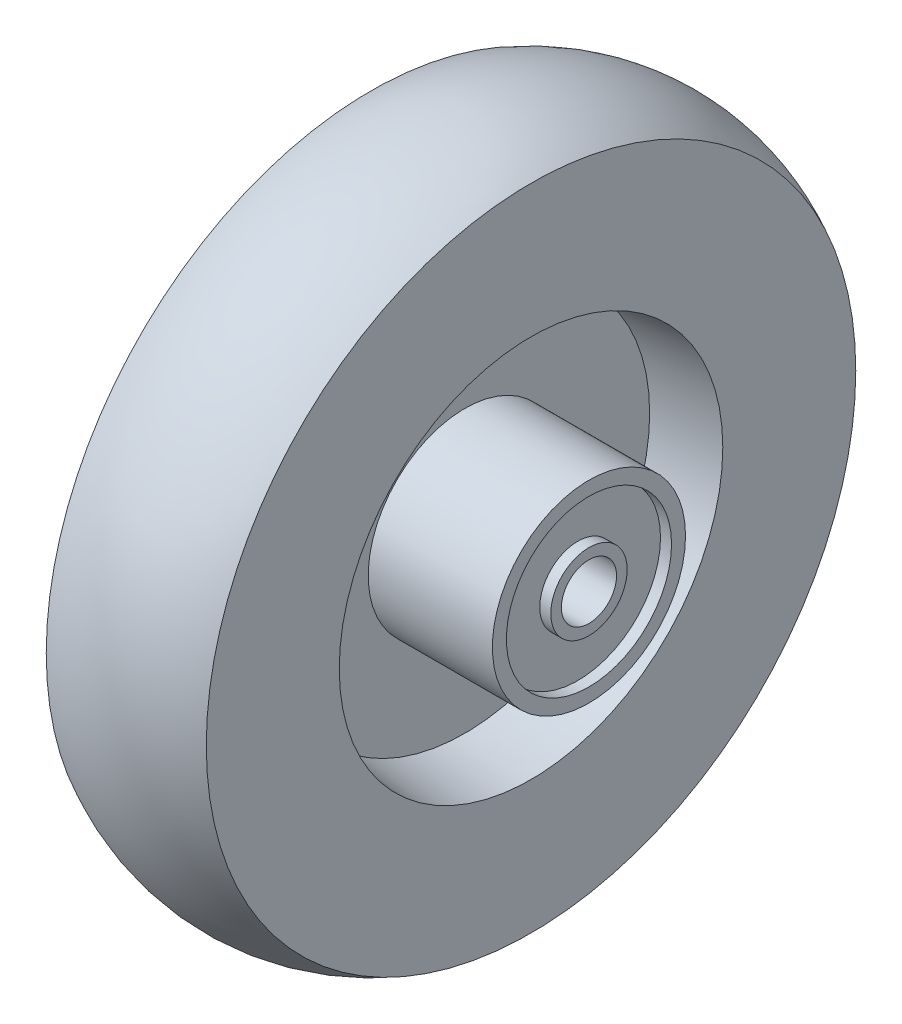
from build123d import *

# Parameters (mm, degrees)
SKETCH2_R          = 19.001809039
SKETCH2_R_2        = 8.788318948
CUT_EXTRUDE1_DEPTH = 2.54
SKETCH3_R          = 6.35
CUT_EXTRUDE2_DEPTH = 64.5


with BuildPart() as part:
    # Sketch1 → Revolve1 (revolve)
    with BuildSketch(Plane(origin=(0, 0, 0), x_dir=(1, 0, 0), z_dir=(0, 1, 0))):
        with BuildLine():
            Line((-31.75, 22.225), (-31.75, 0))
            Line((-31.75, 0), (31.75, 0))
            Line((31.75, 0), (31.75, 22.225))
            Line((31.75, 22.225), (3.175, 22.225))
            Line((3.175, 22.225), (3.175, 42.545))
            Line((3.175, 42.545), (18.415, 44.136059808))
            Line((18.415, 44.136059808), (18.415, 74.737433252))
            ThreePointArc((18.415, 74.737433252), (0, 79.375), (-18.415, 74.737433252))
            Line((-18.415, 74.737433252), (-18.415, 44.136059808))
            Line((-18.415, 44.136059808), (-3.175, 42.545))
            Line((-3.175, 42.545), (-3.175, 22.225))
            Line((-3.175, 22.225), (-31.75, 22.225))
        make_face()
    revolve(axis=Axis((-31.75, 0, 0), (-1, 0, 0)))

    # Sketch2 → Cut-Extrude1 (cut)
    with BuildSketch(Plane(origin=(31.75, 0, 0), x_dir=(0, 0, -1), z_dir=(1, 0, 0))):
        Circle(SKETCH2_R)
        Circle(SKETCH2_R_2, mode=Mode.SUBTRACT)
    cut_extrude1 = extrude(amount=-CUT_EXTRUDE1_DEPTH, mode=Mode.SUBTRACT)

    # Sketch3 → Cut-Extrude2 (cut, through all)
    with BuildSketch(Plane(origin=(31.75, 0, 0), x_dir=(0, 0, -1), z_dir=(1, 0, 0))):
        Circle(SKETCH3_R)
    extrude(amount=-CUT_EXTRUDE2_DEPTH, mode=Mode.SUBTRACT)

    # Mirror3: Cut-Extrude1 across plane
    add(cut_extrude1.mirror(Plane(origin=(0, 0, 0), x_dir=(0, 0, 1), z_dir=(1, 0, 0))), mode=Mode.SUBTRACT)


solid = part.part
